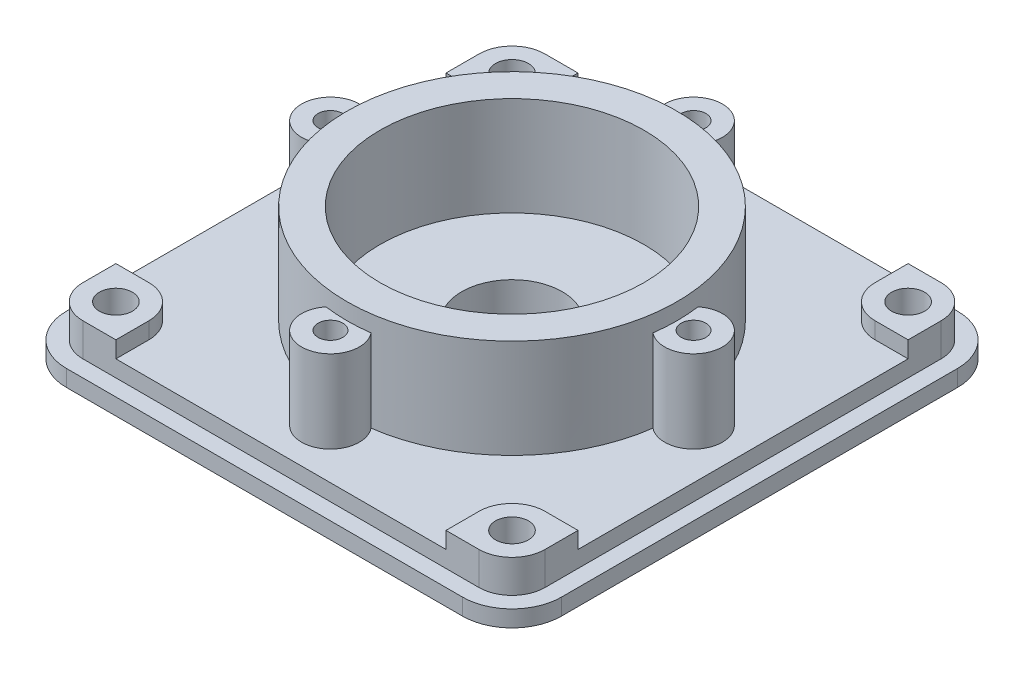
from build123d import *

# Parameters (mm, degrees)
SKETCH1_R           = 6.1
BOSS_EXTRUDE1_DEPTH = 4
BOSS_EXTRUDE2_START = 4
SKETCH1_3_R         = 20
SKETCH1_3_R_2       = 16
BOSS_EXTRUDE2_DEPTH = 12
BOSS_EXTRUDE3_DEPTH = 2
SKETCH1_5_R         = 2
BOSS_EXTRUDE4_DEPTH = 6
BOSS_EXTRUDE5_START = 4
SKETCH1_6_R         = 1.5
BOSS_EXTRUDE5_DEPTH = 10


with BuildPart() as part:
    # Sketch1 → Boss-Extrude1 (new body)
    with BuildSketch(Plane(origin=(0, 0, 0), x_dir=(1, 0, 0), z_dir=(0, 1, 0))):
        with BuildLine():
            Line((-24, 20), (-28, 20))
            Line((-28, 20), (-28, -20))
            Line((-28, -20), (-24, -20))
            ThreePointArc((-24, -20), (-21.171572875, -21.171572875), (-20, -24))
            Line((-20, -24), (-20, -28))
            Line((-20, -28), (20, -28))
            Line((20, -28), (20, -24))
            ThreePointArc((20, -24), (21.171572875, -21.171572875), (24, -20))
            Line((24, -20), (28, -20))
            Line((28, -20), (28, 20))
            Line((28, 20), (24, 20))
            ThreePointArc((24, 20), (21.171572875, 21.171572875), (20, 24))
            Line((20, 24), (20, 28))
            Line((20, 28), (-20, 28))
            Line((-20, 28), (-20, 24))
            ThreePointArc((-20, 24), (-21.171572875, 21.171572875), (-24, 20))
        make_face()
        Circle(SKETCH1_R, mode=Mode.SUBTRACT)
    extrude(amount=BOSS_EXTRUDE1_DEPTH)

    # Sketch1_3 → Boss-Extrude2 (add)
    with BuildSketch(Plane(origin=(0, 0, 0), x_dir=(1, 0, 0), z_dir=(0, 1, 0)).offset(BOSS_EXTRUDE2_START)):
        Circle(SKETCH1_3_R)
        Circle(SKETCH1_3_R_2, mode=Mode.SUBTRACT)
    extrude(amount=BOSS_EXTRUDE2_DEPTH)

    # Sketch1_4 → Boss-Extrude3 (add)
    with BuildSketch(Plane(origin=(0, 0, 0), x_dir=(1, 0, 0), z_dir=(0, 1, 0))):
        with BuildLine():
            Line((24, 30), (-24, 30))
            ThreePointArc((-24, 30), (-28.242640687, 28.242640687), (-30, 24))
            Line((-30, 24), (-30, -24))
            ThreePointArc((-30, -24), (-28.242640687, -28.242640687), (-24, -30))
            Line((-24, -30), (24, -30))
            ThreePointArc((24, -30), (28.242640687, -28.242640687), (30, -24))
            Line((30, -24), (30, 24))
            ThreePointArc((30, 24), (28.242640687, 28.242640687), (24, 30))
        make_face()
        with BuildLine():
            Line((-28, 20), (-28, 24))
            ThreePointArc((-28, 24), (-26.828427125, 26.828427125), (-24, 28))
            Line((-24, 28), (-20, 28))
            Line((-20, 28), (20, 28))
            Line((20, 28), (24, 28))
            ThreePointArc((24, 28), (26.828427125, 26.828427125), (28, 24))
            Line((28, 24), (28, 20))
            Line((28, 20), (28, -20))
            Line((28, -20), (28, -24))
            ThreePointArc((28, -24), (26.828427125, -26.828427125), (24, -28))
            Line((24, -28), (20, -28))
            Line((20, -28), (-20, -28))
            Line((-20, -28), (-24, -28))
            ThreePointArc((-24, -28), (-26.828427125, -26.828427125), (-28, -24))
            Line((-28, -24), (-28, -20))
            Line((-28, -20), (-28, 20))
        make_face(mode=Mode.SUBTRACT)
    extrude(amount=BOSS_EXTRUDE3_DEPTH)

    # Sketch1_5 → Boss-Extrude4 (add)
    with BuildSketch(Plane(origin=(0, 0, 0), x_dir=(1, 0, 0), z_dir=(0, 1, 0))):
        with BuildLine():
            Line((-24, -20), (-28, -20))
            Line((-28, -20), (-28, -24))
            ThreePointArc((-28, -24), (-26.828427125, -26.828427125), (-24, -28))
            Line((-24, -28), (-20, -28))
            Line((-20, -28), (-20, -24))
            ThreePointArc((-20, -24), (-21.171572875, -21.171572875), (-24, -20))
        make_face()
        with Locations((-24, -24)):
            Circle(SKETCH1_5_R, mode=Mode.SUBTRACT)
        with BuildLine():
            Line((20, -24), (20, -28))
            Line((20, -28), (24, -28))
            ThreePointArc((24, -28), (26.828427125, -26.828427125), (28, -24))
            Line((28, -24), (28, -20))
            Line((28, -20), (24, -20))
            ThreePointArc((24, -20), (21.171572875, -21.171572875), (20, -24))
        make_face()
        with Locations((24, -24)):
            Circle(SKETCH1_5_R, mode=Mode.SUBTRACT)
        with BuildLine():
            Line((24, 28), (20, 28))
            Line((20, 28), (20, 24))
            ThreePointArc((20, 24), (21.171572875, 21.171572875), (24, 20))
            Line((24, 20), (28, 20))
            Line((28, 20), (28, 24))
            ThreePointArc((28, 24), (26.828427125, 26.828427125), (24, 28))
        make_face()
        with Locations((24, 24)):
            Circle(SKETCH1_5_R, mode=Mode.SUBTRACT)
        with BuildLine():
            ThreePointArc((-24, 28), (-26.828427125, 26.828427125), (-28, 24))
            Line((-28, 24), (-28, 20))
            Line((-28, 20), (-24, 20))
            ThreePointArc((-24, 20), (-21.171572875, 21.171572875), (-20, 24))
            Line((-20, 24), (-20, 28))
            Line((-20, 28), (-24, 28))
        make_face()
        with Locations((-24, 24)):
            Circle(SKETCH1_5_R, mode=Mode.SUBTRACT)
    extrude(amount=BOSS_EXTRUDE4_DEPTH)

    # Sketch1_6 → Boss-Extrude5 (add)
    with BuildSketch(Plane(origin=(0, 0, 0), x_dir=(1, 0, 0), z_dir=(0, 1, 0)).offset(BOSS_EXTRUDE5_START)):
        with BuildLine():
            ThreePointArc((-2.732186624, -19.8125), (0, -25.5), (2.732186624, -19.8125))
            ThreePointArc((2.732186624, -19.8125), (0, -20), (-2.732186624, -19.8125))
        make_face()
        with Locations((0, -22)):
            Circle(SKETCH1_6_R, mode=Mode.SUBTRACT)
        with BuildLine():
            ThreePointArc((-19.8125, -2.732186624), (-20, 0), (-19.8125, 2.732186624))
            ThreePointArc((-19.8125, 2.732186624), (-25.5, 0), (-19.8125, -2.732186624))
        make_face()
        with Locations((-22, 0)):
            Circle(SKETCH1_6_R, mode=Mode.SUBTRACT)
        with BuildLine():
            ThreePointArc((-2.732186624, 19.8125), (0, 20), (2.732186624, 19.8125))
            ThreePointArc((2.732186624, 19.8125), (0, 25.5), (-2.732186624, 19.8125))
        make_face()
        with Locations((0, 22)):
            Circle(SKETCH1_6_R, mode=Mode.SUBTRACT)
        with BuildLine():
            ThreePointArc((19.8125, 2.732186624), (19.953069939, 1.369306394), (20, 0))
            ThreePointArc((20, 0), (19.953069939, -1.369306394), (19.8125, -2.732186624))
            ThreePointArc((19.8125, -2.732186624), (25.5, 0), (19.8125, 2.732186624))
        make_face()
        with Locations((22, 0)):
            Circle(SKETCH1_6_R, mode=Mode.SUBTRACT)
    extrude(amount=BOSS_EXTRUDE5_DEPTH)


solid = part.part
